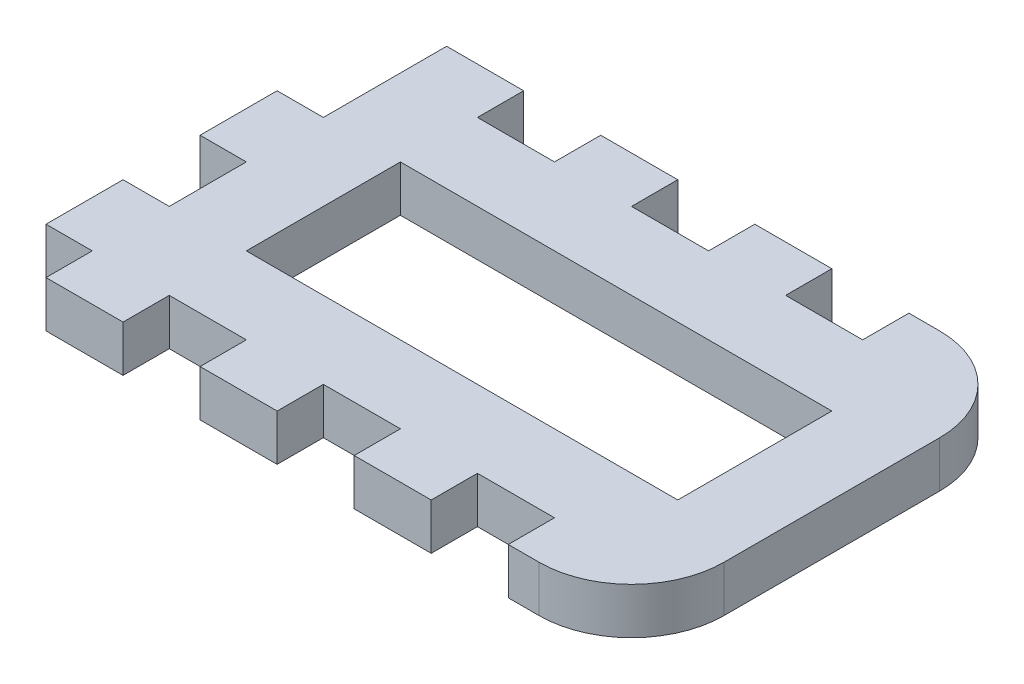
from build123d import *

# Parameters (mm, degrees)
SKETCH1_W           = 38
SKETCH1_H           = 26
BOSS_EXTRUDE1_DEPTH = 1.5
SKETCH8_W           = 5
SKETCH8_H           = 3
BOSS_EXTRUDE2_DEPTH = 3
SKETCH9_W           = 5
SKETCH9_H           = 3
CUT_EXTRUDE2_DEPTH  = 3
FILLET1_R           = 6
SKETCH10_W          = 28
SKETCH10_H          = 10
CUT_EXTRUDE3_DEPTH  = 3


with BuildPart() as part:
    # Sketch1 → Boss-Extrude1 (new body, symmetric)
    with BuildSketch(Plane(origin=(0, 0, 0), x_dir=(1, 0, 0), z_dir=(0, 1, 0))):
        Rectangle(SKETCH1_W, SKETCH1_H)
    extrude(amount=BOSS_EXTRUDE1_DEPTH, both=True)

    # Sketch8 → Boss-Extrude2 (add)
    with BuildSketch(Plane.ZY.offset(19)):
        with Locations((-2.5, 0)):
            Rectangle(SKETCH8_W, SKETCH8_H)
        with Locations((7.5, 0)):
            Rectangle(SKETCH8_W, SKETCH8_H)
    extrude(amount=BOSS_EXTRUDE2_DEPTH)

    # Sketch9 → Cut-Extrude2 (cut)
    with BuildSketch(Plane.XZ.offset(1.5)):
        with Locations((-11.5, -11.5)):
            Rectangle(SKETCH9_W, SKETCH9_H)
        with Locations((-11.5, 11.5)):
            Rectangle(SKETCH9_W, SKETCH9_H)
        with Locations((-1.5, -11.5)):
            Rectangle(SKETCH9_W, SKETCH9_H)
        with Locations((-1.5, 11.5)):
            Rectangle(SKETCH9_W, SKETCH9_H)
        with Locations((8.5, -11.5)):
            Rectangle(SKETCH9_W, SKETCH9_H)
        with Locations((8.5, 11.5)):
            Rectangle(SKETCH9_W, SKETCH9_H)
    extrude(amount=-CUT_EXTRUDE2_DEPTH, mode=Mode.SUBTRACT)

    # Fillet1
    fillet1_edges = [part.edges().sort_by_distance(p)[0] for p in [
        (19, 0, 13),
        (19, 0, -13),
    ]]
    fillet(fillet1_edges, radius=FILLET1_R)

    # Sketch10 → Cut-Extrude3 (cut)
    with BuildSketch(Plane(origin=(0, 1.5, 0), x_dir=(1, 0, 0), z_dir=(0, 1, 0))):
        Rectangle(SKETCH10_W, SKETCH10_H)
    extrude(amount=-CUT_EXTRUDE3_DEPTH, mode=Mode.SUBTRACT)


solid = part.part
